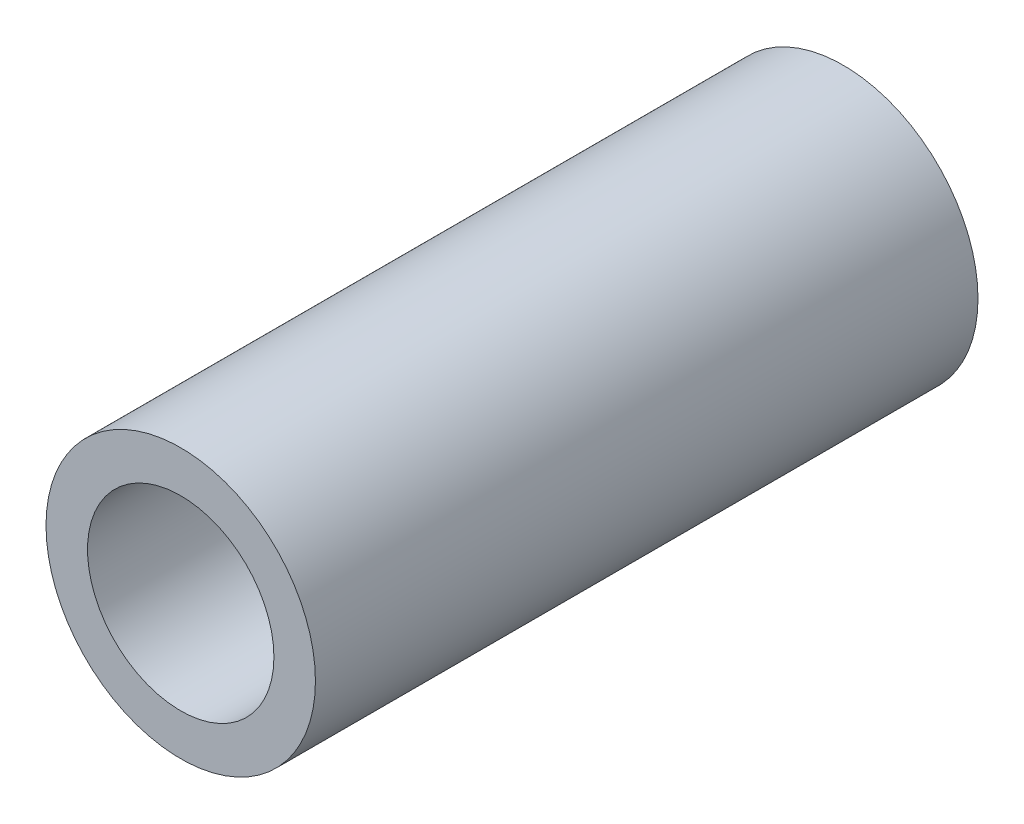
from build123d import *

# Parameters (mm, degrees)
SKETCH1_R           = 7.747
SKETCH1_R_2         = 5.3594
BOSS_EXTRUDE1_DEPTH = 38.1


with BuildPart() as part:
    # Sketch1 → Boss-Extrude1 (new body)
    with BuildSketch(Plane.XY):
        Circle(SKETCH1_R)
        Circle(SKETCH1_R_2, mode=Mode.SUBTRACT)
    extrude(amount=BOSS_EXTRUDE1_DEPTH)


solid = part.part
